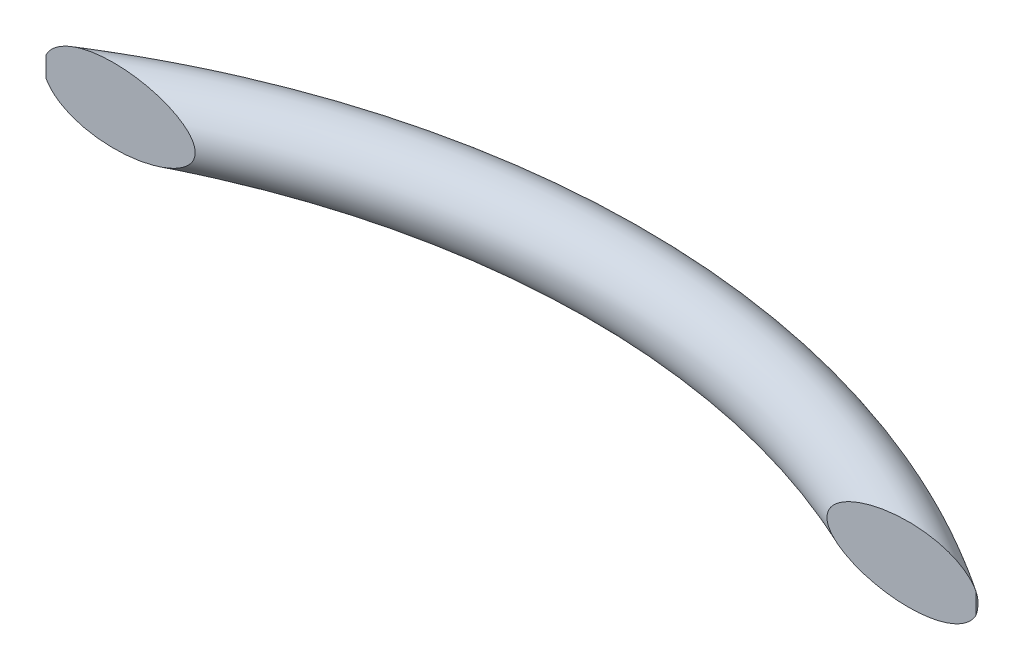
from build123d import *

# Parameters (mm, degrees)
SKETCH2_R               = 12.7
SKETCH3_W               = 432.664370001
SKETCH3_H               = 238.427735242
CUT_EXTRUDE2_DEPTH      = 59.182
CUT_EXTRUDE2_DEPTH_BACK = 10.16


with BuildPart() as part:
    # Sweep1: sweep along a path in Sketch1
    with BuildLine(Plane(origin=(0, 0, 0), x_dir=(1, 0, 0), z_dir=(0, 1, 0))) as sweep1_path:
        ThreePointArc((-304.8, 0), (-152.4, 46.272842814), (0, 0))
    # Sketch2 → Sweep1 (sweep)
    with BuildSketch(Plane(origin=(0, 0, 0), x_dir=(0.555997875, 0, -0.831183712), z_dir=(0.831183712, 0, 0.555997875))):
        Circle(SKETCH2_R)
    sweep(path=sweep1_path.line)

    # Sketch3 → Cut-Extrude2 (cut, two sides)
    with BuildSketch(Plane.XY) as cut_extrude2_sk:
        with Locations((-163.393278764, 0)):
            Rectangle(SKETCH3_W, SKETCH3_H)
    extrude(amount=CUT_EXTRUDE2_DEPTH, mode=Mode.SUBTRACT)
    extrude(cut_extrude2_sk.sketch, amount=-CUT_EXTRUDE2_DEPTH_BACK, mode=Mode.SUBTRACT)


solid = part.part
